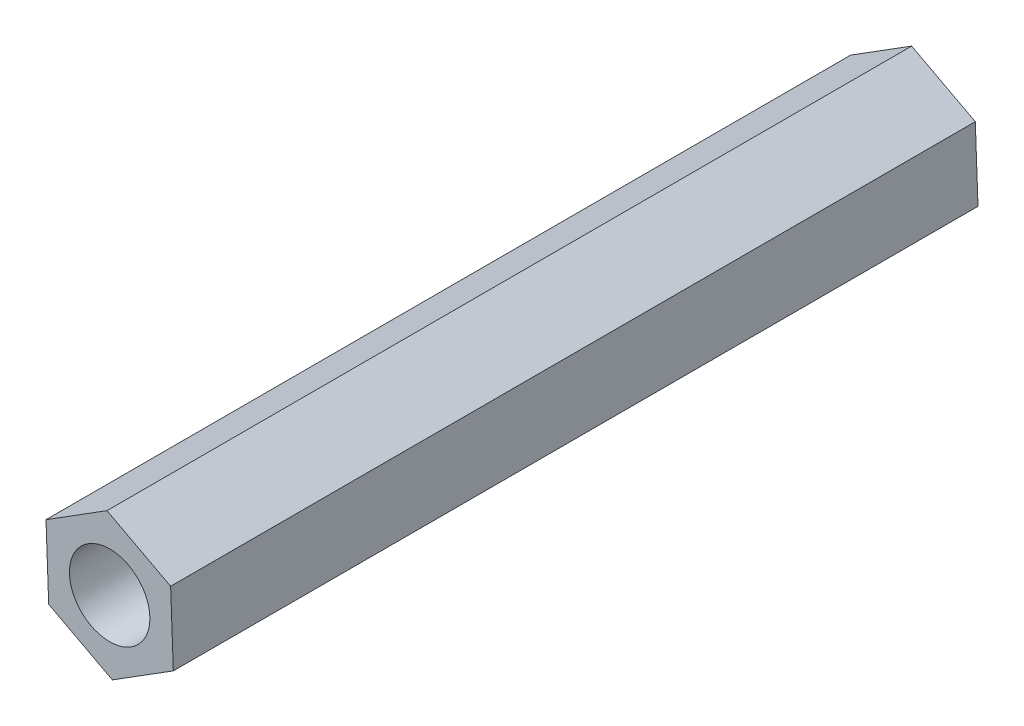
from build123d import *

# Parameters (mm, degrees)
SKETCH_1_R      = 1.5
EXTRUDE_1_DEPTH = 30


with BuildPart() as part:
    # 草图1 → 凸台-拉伸1 (new body)
    with BuildSketch(Plane.XY):
        Polygon((2.273206082, 1.428297627), (-0.100338988, 2.682803028), (-2.37354507, 1.254505402), (-2.273206082, -1.428297627), (0.100338988, -2.682803028), (2.37354507, -1.254505402), align=None)
        Circle(SKETCH_1_R, mode=Mode.SUBTRACT)
    extrude(amount=EXTRUDE_1_DEPTH)


solid = part.part
